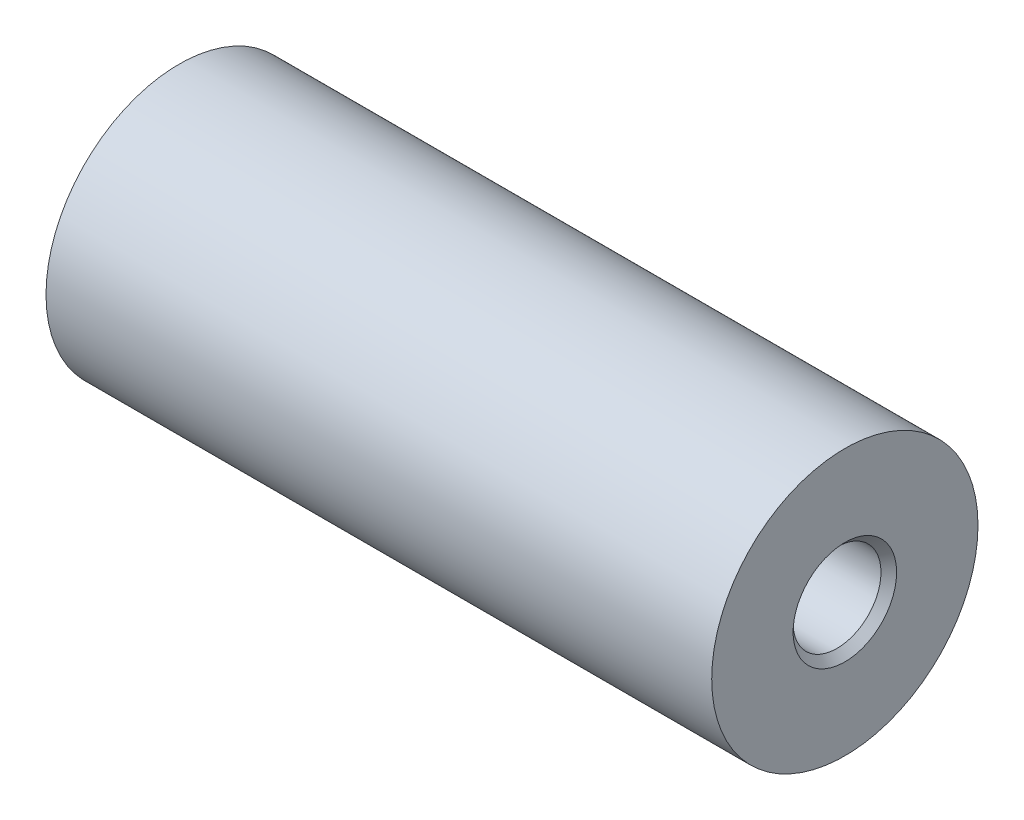
from build123d import *

# Parameters (mm, degrees)
SKETCH_1_R                      = 10
EXTRUDE_1_DEPTH                 = 50
HOLE_WIZARD_G1_16_2_D           = 6.6
HOLE_WIZARD_G1_16_2_DEPTH       = 50
HOLE_WIZARD_G1_16_2_CSINK_D     = 7.773
HOLE_WIZARD_G1_16_2_CSINK_ANGLE = 90
HOLE_WIZARD_G1_16_2_TIP         = 1.982840043


with BuildPart() as part:
    # 草图1 → 凸台-拉伸1 (new body)
    with BuildSketch(Plane(origin=(0, 0, 0), x_dir=(0, 0, -1), z_dir=(1, 0, 0))):
        Circle(SKETCH_1_R)
    extrude(amount=EXTRUDE_1_DEPTH)

    # G1/16 螺纹孔2
    with Locations(Plane(origin=(50, 0, 0), x_dir=(0, 0, -1), z_dir=(1, 0, 0))):
        with Locations((0, 0)):
            CounterSinkHole(HOLE_WIZARD_G1_16_2_D / 2, HOLE_WIZARD_G1_16_2_CSINK_D / 2, depth=HOLE_WIZARD_G1_16_2_DEPTH, counter_sink_angle=HOLE_WIZARD_G1_16_2_CSINK_ANGLE)
            with Locations((0, 0, -(HOLE_WIZARD_G1_16_2_DEPTH + HOLE_WIZARD_G1_16_2_TIP / 2))):  # 118° drill point
                Cone(0, HOLE_WIZARD_G1_16_2_D / 2, HOLE_WIZARD_G1_16_2_TIP, mode=Mode.SUBTRACT)


solid = part.part
